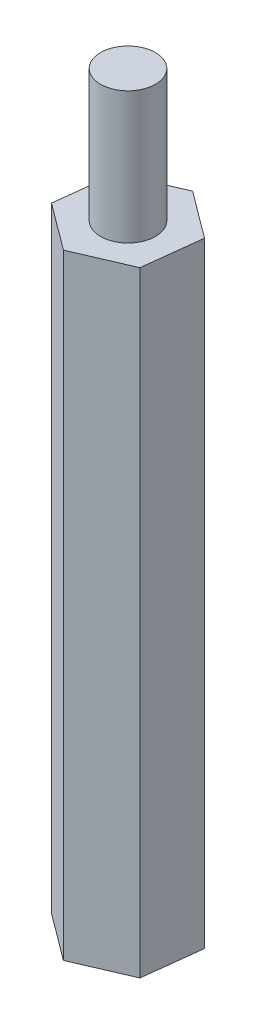
from build123d import *

# Parameters (mm, degrees)
EXTRUDE_1_DEPTH     = 28
SKETCH_2_R          = 1.25
EXTRUDE_2_DEPTH     = 6
SKETCH_3_R          = 1.25
CUT_EXTRUDE_1_DEPTH = 6


with BuildPart() as part:
    # 草图1 → 凸台-拉伸1 (new body)
    with BuildSketch(Plane(origin=(0, 0, 0), x_dir=(1, 0, 0), z_dir=(0, 1, 0))):
        Polygon((2.125123473, -1.583145674), (2.433606108, 1.048838076), (0.308482635, 2.631983751), (-2.125123473, 1.583145674), (-2.433606108, -1.048838076), (-0.308482635, -2.631983751), align=None)
    extrude(amount=EXTRUDE_1_DEPTH)

    # 草图2 → 凸台-拉伸2 (add)
    with BuildSketch(Plane(origin=(0, 28, 0), x_dir=(1, 0, 0), z_dir=(0, 1, 0))):
        Circle(SKETCH_2_R)
    extrude(amount=EXTRUDE_2_DEPTH)

    # 草图3 → 切除-拉伸1 (cut)
    with BuildSketch(Plane.XZ):
        Circle(SKETCH_3_R)
    extrude(amount=-CUT_EXTRUDE_1_DEPTH, mode=Mode.SUBTRACT)


solid = part.part
